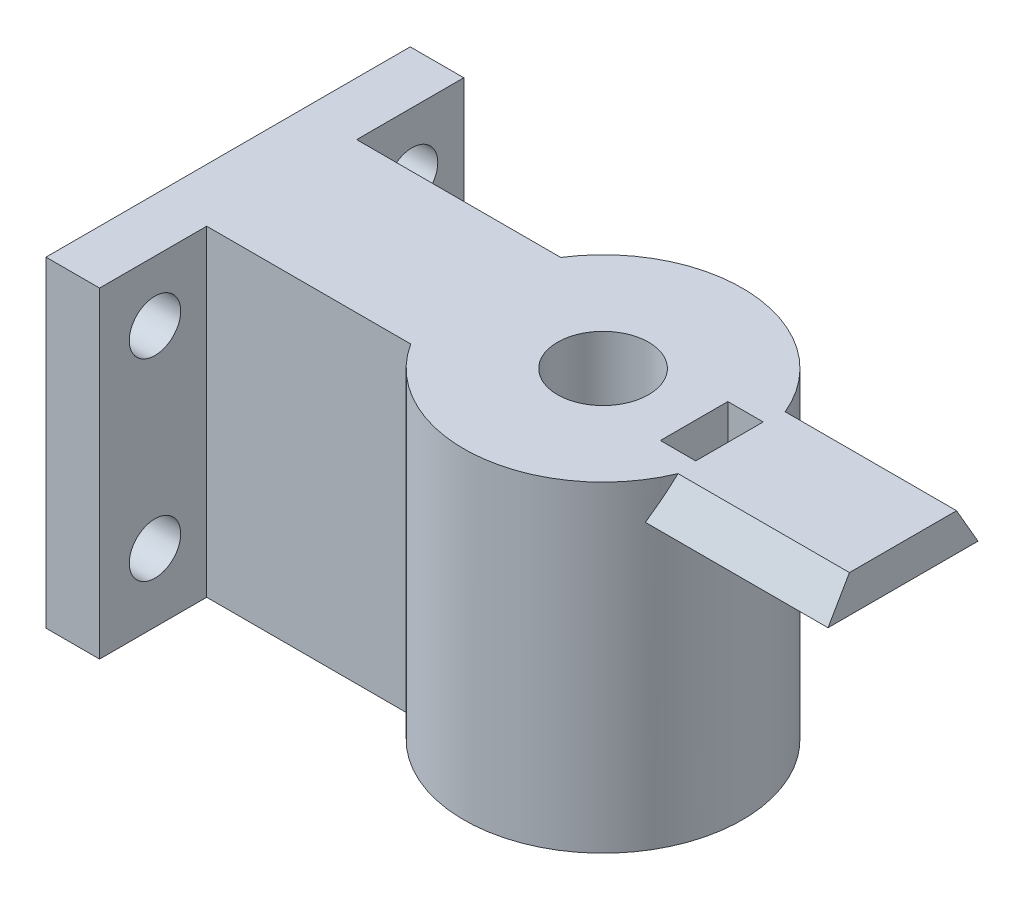
from build123d import *

# Parameters (mm, degrees)
SKETCH2_R                            = 4.25
BOSS_EXTRUDE1_DEPTH                  = 30
SKETCH3_R                            = 11.25
SKETCH3_R_2                          = 5.25
SKETCH3_R_3                          = 4.25
CUT_EXTRUDE1_DEPTH                   = 5
CUT_EXTRUDE2_START                   = -5
SKETCH3_3_R                          = 5.25
SKETCH3_3_R_2                        = 4.25
CUT_EXTRUDE2_DEPTH                   = 10.6
SKETCH4_R                            = 2.4
CUT_EXTRUDE3_DEPTH                   = 56.118055118
SKETCH5_R                            = 1.3
CUT_EXTRUDE4_DEPTH                   = 6
SKETCH5_3_R                          = 1.3
BOSS_EXTRUDE2_DEPTH                  = 3.6
BOSS_EXTRUDE3_DEPTH                  = 15
BOSS_EXTRUDE3_DIRECTION_2_REACH      = 61.102
BOSS_EXTRUDE3_DIRECTION_2_END_RADIUS = 13
CUT_EXTRUDE5_START                   = -1.2
CUT_EXTRUDE5_DEPTH                   = 3.3


with BuildPart() as part:
    # Sketch2 → Boss-Extrude1 (new body)
    with BuildSketch(Plane(origin=(0, 0, 0), x_dir=(1, 0, 0), z_dir=(0, 1, 0))):
        with BuildLine():
            Line((0, 17), (0, -17))
            Line((0, -17), (5, -17))
            Line((5, -17), (5, -7))
            Line((5, -7), (24.04554885, -7))
            ThreePointArc((24.04554885, -7), (48, 0), (24.04554885, 7))
            Line((24.04554885, 7), (5, 7))
            Line((5, 7), (5, 17))
            Line((5, 17), (0, 17))
        make_face()
        with Locations(Location((35, 0, 0), (0, 0, 270))):
            Circle(SKETCH2_R, mode=Mode.SUBTRACT)
    extrude(amount=BOSS_EXTRUDE1_DEPTH)

    # Sketch3 → Cut-Extrude1 (cut)
    with BuildSketch(Plane.XZ):
        with Locations(Location((35, 0, 0), (0, 0, 270))):
            Circle(SKETCH3_R)
        with Locations((35, 0)):
            Circle(SKETCH3_R_2, mode=Mode.SUBTRACT)
        with Locations((35, 0)):
            Circle(SKETCH3_R_2)
        with Locations(Location((35, 0, 0), (0, 0, 270))):
            Circle(SKETCH3_R_3, mode=Mode.SUBTRACT)
    extrude(amount=-CUT_EXTRUDE1_DEPTH, mode=Mode.SUBTRACT)

    # Sketch3_3 → Cut-Extrude2 (cut)
    with BuildSketch(Plane.XZ.offset(CUT_EXTRUDE2_START)):
        with Locations(Location((35, 0, 0), (0, 0, 270))):
            Circle(SKETCH3_3_R)
        with Locations(Location((35, 0, 0), (0, 0, 270))):
            Circle(SKETCH3_3_R_2, mode=Mode.SUBTRACT)
    extrude(amount=-CUT_EXTRUDE2_DEPTH, mode=Mode.SUBTRACT)

    # Sketch4 → Cut-Extrude3 (cut, through all)
    with BuildSketch(Plane(origin=(5, 0, 0), x_dir=(0, 0, -1), z_dir=(1, 0, 0))):
        with Locations((12.17186788, 24.363439063)):
            Circle(SKETCH4_R)
        with Locations((12.17186788, 6.363439063)):
            Circle(SKETCH4_R)
        with Locations((-11.82813212, 6.363439063)):
            Circle(SKETCH4_R)
        with Locations((-11.82813212, 24.363439063)):
            Circle(SKETCH4_R)
    extrude(amount=-CUT_EXTRUDE3_DEPTH, mode=Mode.SUBTRACT)

    # Sketch5 → Cut-Extrude4 (cut)
    with BuildSketch(Plane.XZ.offset(-5)):
        with Locations(Location((35, 8, 0), (0, 0, 270))):
            Circle(SKETCH5_R)
        with Locations(Location((35, -8, 0), (0, 0, 270))):
            Circle(SKETCH5_R)
    extrude(amount=-CUT_EXTRUDE4_DEPTH, mode=Mode.SUBTRACT)

    # Sketch5_3 → Boss-Extrude2 (add)
    with BuildSketch(Plane.XZ.offset(-5)):
        with Locations(Location((27, 0, 0), (0, 0, 270))):
            Circle(SKETCH5_3_R)
        with Locations(Location((43, 0, 0), (0, 0, 270))):
            Circle(SKETCH5_3_R)
    extrude(amount=BOSS_EXTRUDE2_DEPTH)


with BuildPart() as boss_extrude3_tool:
    # Sketch7 → Boss-Extrude3 (new body)
    with BuildSketch(Plane(origin=(48, 0, 0), x_dir=(0, 0, -1), z_dir=(1, 0, 0))):
        Polygon((-5, 30), (5, 30), (7, 26.535898385), (-7, 26.535898385), align=None)
    extrude(amount=BOSS_EXTRUDE3_DEPTH)


with BuildPart() as part_1:
    add(part.part)


with BuildPart() as part_2:
    # Boss-Extrude3: joined with boss_extrude3_tool
    add(part_1.part.fuse(boss_extrude3_tool.part, tol=0.00001))

    # Boss-Extrude3 direction 2: up to this cylinder (the profile starts outside it)
    boss_extrude3_direction_2_end = Plane(origin=(35, 28.171724, 0), z_dir=(0, -1, 0)) * Cylinder(BOSS_EXTRUDE3_DIRECTION_2_END_RADIUS, 149.204, mode=Mode.PRIVATE)
    # Sketch7 → Boss-Extrude3 direction 2 (add, up to the surface)
    with BuildSketch(Plane(origin=(48, 0, 0), x_dir=(0, 0, -1), z_dir=(1, 0, 0)), mode=Mode.PRIVATE) as boss_extrude3_direction_2_sk1:
        Polygon((-5, 30), (5, 30), (7, 26.535898385), (-7, 26.535898385), align=None)
    boss_extrude3_direction_2_tool1 = extrude(boss_extrude3_direction_2_sk1.sketch, amount=-BOSS_EXTRUDE3_DIRECTION_2_REACH, mode=Mode.PRIVATE) - boss_extrude3_direction_2_end
    add(boss_extrude3_direction_2_tool1.solids().sort_by_distance((48, 28.171724, 0))[0])
    add(boss_extrude3_direction_2_tool1.solids().sort_by_distance((48, 28.171724, 0))[1])

    # Sketch9 → Cut-Extrude5 (cut)
    with BuildSketch(Plane(origin=(48, 0, 0), x_dir=(0, 0, -1), z_dir=(1, 0, 0)).offset(CUT_EXTRUDE5_START)):
        with BuildLine():
            Line((3.15, 30.472989279), (3.15, 9.535898385))
            ThreePointArc((3.15, 9.535898385), (0, 6.385898385), (-3.15, 9.535898385))
            Line((-3.15, 9.535898385), (-3.15, 30.472989279))
            ThreePointArc((-3.15, 30.472989279), (0, 33.622989279), (3.15, 30.472989279))
        make_face()
    extrude(amount=-CUT_EXTRUDE5_DEPTH, mode=Mode.SUBTRACT)


solid = part_2.part
